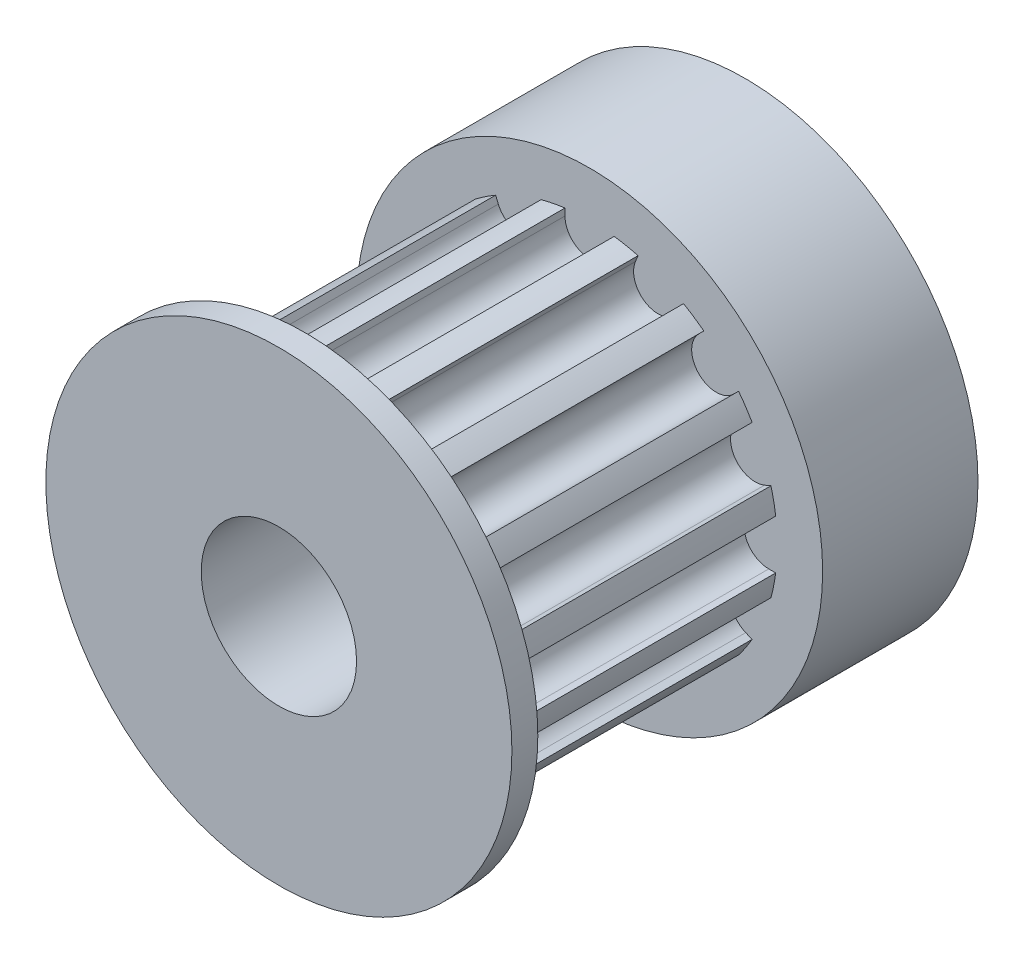
from build123d import *

# Parameters (mm, degrees)
SKETCH1_R           = 9
SKETCH1_R_2         = 3
BOSS_EXTRUDE1_DEPTH = 6
SKETCH2_R           = 7.25
SKETCH2_R_2         = 3
BOSS_EXTRUDE2_DEPTH = 11
SKETCH3_R           = 9
SKETCH3_R_2         = 3
BOSS_EXTRUDE3_DEPTH = 1
SKETCH4_R           = 1.5
CUT_EXTRUDE1_DEPTH  = 10
CUT_EXTRUDE4_START  = -1
SKETCH5_R           = 9
CUT_EXTRUDE4_DEPTH  = 11


with BuildPart() as part:
    # Sketch1 → Boss-Extrude1 (new body)
    with BuildSketch(Plane.XY):
        Circle(SKETCH1_R)
        Circle(SKETCH1_R_2, mode=Mode.SUBTRACT)
    extrude(amount=BOSS_EXTRUDE1_DEPTH)

    # Sketch2 → Boss-Extrude2 (add)
    with BuildSketch(Plane.XY.offset(6)):
        Circle(SKETCH2_R)
        Circle(SKETCH2_R_2, mode=Mode.SUBTRACT)
    extrude(amount=BOSS_EXTRUDE2_DEPTH)

    # Sketch3 → Boss-Extrude3 (add)
    with BuildSketch(Plane.XY.offset(17)):
        Circle(SKETCH3_R)
        Circle(SKETCH3_R_2, mode=Mode.SUBTRACT)
    extrude(amount=BOSS_EXTRUDE3_DEPTH)

    # Sketch4 → Cut-Extrude1 (cut, through all)
    with BuildSketch(Plane(origin=(0, 0, 0), x_dir=(1, 0, 0), z_dir=(0, 1, 0))):
        with Locations((0, -4)):
            Circle(SKETCH4_R)
    extrude(amount=-CUT_EXTRUDE1_DEPTH, mode=Mode.SUBTRACT)

    # Sketch5 → Cut-Extrude4 (cut)
    with BuildSketch(Plane.XY.offset(18).offset(CUT_EXTRUDE4_START)):
        Circle(SKETCH5_R)
        with BuildLine():
            Line((-0.95, 7.18748913), (-0.95, 6.92))
            ThreePointArc((-0.95, 6.92), (0, 5.97), (0.95, 6.92))
            Line((0.95, 6.92), (0.95, 7.18748913))
            ThreePointArc((0.95, 7.18748913), (1.414404835, 7.110693283), (1.872847455, 7.003923358))
            Line((1.872847455, 7.003923358), (1.770483796, 6.756795626))
            ThreePointArc((1.770483796, 6.756795626), (2.284620091, 5.515560809), (3.525854908, 6.029697104))
            Line((3.525854908, 6.029697104), (3.628218566, 6.276824837))
            ThreePointArc((3.628218566, 6.276824837), (4.027884188, 6.028154687), (4.410570862, 5.754073746))
            Line((4.410570862, 5.754073746), (4.221427484, 5.564930368))
            ThreePointArc((4.221427484, 5.564930368), (4.221427484, 4.221427484), (5.564930368, 4.221427484))
            Line((5.564930368, 4.221427484), (5.754073746, 4.410570862))
            ThreePointArc((5.754073746, 4.410570862), (6.028154689, 4.027884189), (6.276824837, 3.628218566))
            Line((6.276824837, 3.628218566), (6.029697104, 3.525854908))
            ThreePointArc((6.029697104, 3.525854908), (5.515560809, 2.284620091), (6.756795626, 1.770483796))
            Line((6.756795626, 1.770483796), (7.003923358, 1.872847455))
            ThreePointArc((7.003923358, 1.872847455), (7.110693283, 1.414404835), (7.18748913, 0.95))
            Line((7.18748913, 0.95), (6.92, 0.95))
            ThreePointArc((6.92, 0.95), (5.97, 0), (6.92, -0.95))
            Line((6.92, -0.95), (7.18748913, -0.95))
            ThreePointArc((7.18748913, -0.95), (7.110693283, -1.414404835), (7.003923358, -1.872847455))
            Line((7.003923358, -1.872847455), (6.756795626, -1.770483796))
            ThreePointArc((6.756795626, -1.770483796), (5.515560809, -2.284620091), (6.029697104, -3.525854908))
            Line((6.029697104, -3.525854908), (6.276824837, -3.628218566))
            ThreePointArc((6.276824837, -3.628218566), (6.028154689, -4.027884189), (5.754073746, -4.410570862))
            Line((5.754073746, -4.410570862), (5.564930368, -4.221427484))
            ThreePointArc((5.564930368, -4.221427484), (4.221427484, -4.221427484), (4.221427484, -5.564930368))
            Line((4.221427484, -5.564930368), (4.410570862, -5.754073746))
            ThreePointArc((4.410570862, -5.754073746), (4.027884189, -6.028154689), (3.628218566, -6.276824837))
            Line((3.628218566, -6.276824837), (3.525854908, -6.029697104))
            ThreePointArc((3.525854908, -6.029697104), (2.284620091, -5.515560809), (1.770483796, -6.756795626))
            Line((1.770483796, -6.756795626), (1.872847455, -7.003923358))
            ThreePointArc((1.872847455, -7.003923358), (1.414404835, -7.110693283), (0.95, -7.18748913))
            Line((0.95, -7.18748913), (0.95, -6.92))
            ThreePointArc((0.95, -6.92), (0, -5.97), (-0.95, -6.92))
            Line((-0.95, -6.92), (-0.95, -7.18748913))
            ThreePointArc((-0.95, -7.18748913), (-1.414404835, -7.110693283), (-1.872847455, -7.003923358))
            Line((-1.872847455, -7.003923358), (-1.770483796, -6.756795626))
            ThreePointArc((-1.770483796, -6.756795626), (-2.284620091, -5.515560809), (-3.525854908, -6.029697104))
            Line((-3.525854908, -6.029697104), (-3.628218566, -6.276824837))
            ThreePointArc((-3.628218566, -6.276824837), (-4.027884189, -6.028154689), (-4.410570862, -5.754073746))
            Line((-4.410570862, -5.754073746), (-4.221427484, -5.564930368))
            ThreePointArc((-4.221427484, -5.564930368), (-4.221427484, -4.221427484), (-5.564930368, -4.221427484))
            Line((-5.564930368, -4.221427484), (-5.754073746, -4.410570862))
            ThreePointArc((-5.754073746, -4.410570862), (-6.028154689, -4.027884189), (-6.276824837, -3.628218566))
            Line((-6.276824837, -3.628218566), (-6.029697104, -3.525854908))
            ThreePointArc((-6.029697104, -3.525854908), (-5.515560809, -2.284620091), (-6.756795626, -1.770483796))
            Line((-6.756795626, -1.770483796), (-7.003923358, -1.872847455))
            ThreePointArc((-7.003923358, -1.872847455), (-7.110693283, -1.414404835), (-7.18748913, -0.95))
            Line((-7.18748913, -0.95), (-6.92, -0.95))
            ThreePointArc((-6.92, -0.95), (-5.97, 0), (-6.92, 0.95))
            Line((-6.92, 0.95), (-7.18748913, 0.95))
            ThreePointArc((-7.18748913, 0.95), (-7.110693275, 1.414404833), (-7.003923358, 1.872847455))
            Line((-7.003923358, 1.872847455), (-6.756795626, 1.770483796))
            ThreePointArc((-6.756795626, 1.770483796), (-5.515560809, 2.284620091), (-6.029697104, 3.525854908))
            Line((-6.029697104, 3.525854908), (-6.276824837, 3.628218566))
            ThreePointArc((-6.276824837, 3.628218566), (-6.028154686, 4.027884187), (-5.754073746, 4.410570862))
            Line((-5.754073746, 4.410570862), (-5.564930368, 4.221427484))
            ThreePointArc((-5.564930368, 4.221427484), (-4.221427484, 4.221427484), (-4.221427484, 5.564930368))
            Line((-4.221427484, 5.564930368), (-4.410570862, 5.754073746))
            ThreePointArc((-4.410570862, 5.754073746), (-4.027884189, 6.028154689), (-3.628218566, 6.276824837))
            Line((-3.628218566, 6.276824837), (-3.525854908, 6.029697104))
            ThreePointArc((-3.525854908, 6.029697104), (-2.284620091, 5.515560809), (-1.770483796, 6.756795626))
            Line((-1.770483796, 6.756795626), (-1.872847455, 7.003923358))
            ThreePointArc((-1.872847455, 7.003923358), (-1.414404834, 7.11069328), (-0.95, 7.18748913))
        make_face(mode=Mode.SUBTRACT)
    extrude(amount=-CUT_EXTRUDE4_DEPTH, mode=Mode.SUBTRACT)


solid = part.part
